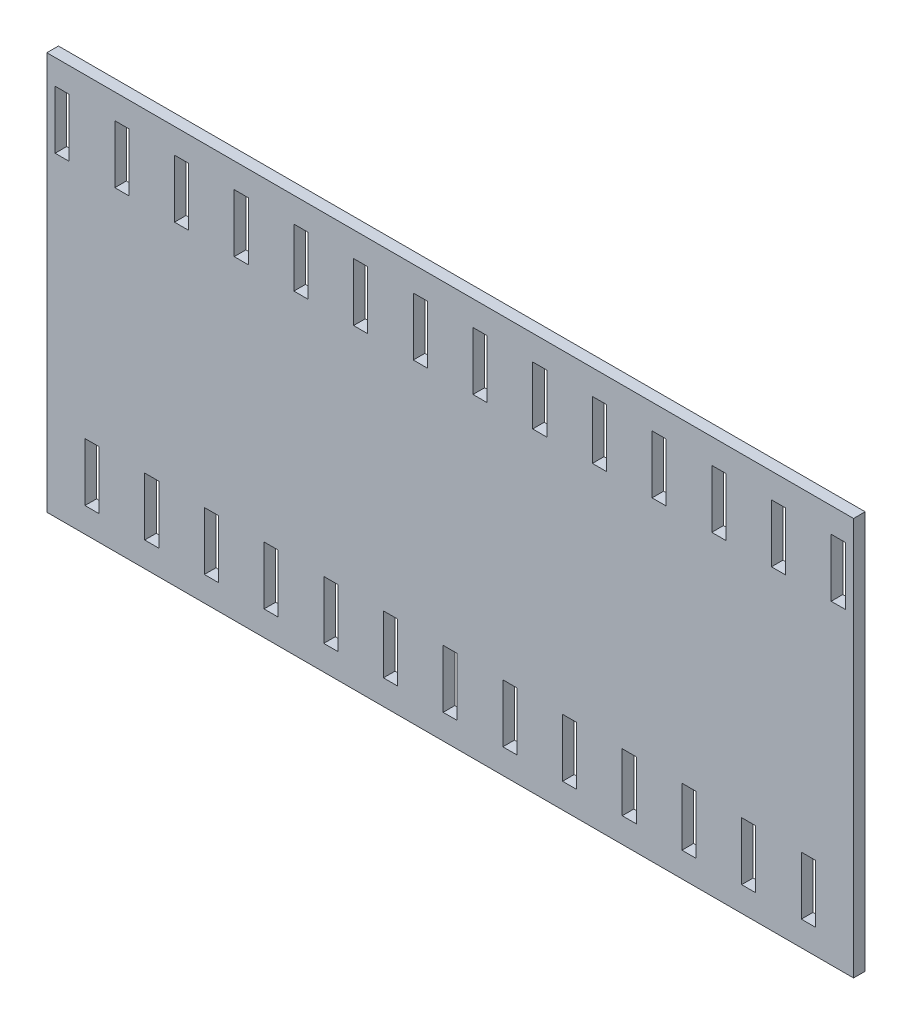
from build123d import *

# Parameters (mm, degrees)
ESQUISSE1_W             = 97.3
ESQUISSE1_H             = 48
BOSS_EXTRU_1_DEPTH      = 1.4
ESQUISSE2_W             = 1.7
ESQUISSE2_H             = 7
ENL_V_MAT_EXTRU_1_DEPTH = 2.4
ESQUISSE3_W             = 0.314102564
ESQUISSE3_H             = 3.5
ENL_V_MAT_EXTRU_2_DEPTH = 0.1


with BuildPart() as part:
    # Esquisse1 → Boss.-Extru.1 (new body)
    with BuildSketch(Plane.XY):
        Rectangle(ESQUISSE1_W, ESQUISSE1_H)
    extrude(amount=BOSS_EXTRU_1_DEPTH)

    # Esquisse2 → Enlèv. mat.-Extru.1 (cut, through all)
    with BuildSketch(Plane(origin=(0, 0, 0), x_dir=(-1, 0, 0), z_dir=(0, 0, -1))):
        with Locations((-46.8, 17.5)):
            Rectangle(ESQUISSE2_W, ESQUISSE2_H)
        with Locations((-39.6, 17.5)):
            Rectangle(ESQUISSE2_W, ESQUISSE2_H)
        with Locations((-32.4, 17.5)):
            Rectangle(ESQUISSE2_W, ESQUISSE2_H)
        with Locations((-25.2, 17.5)):
            Rectangle(ESQUISSE2_W, ESQUISSE2_H)
        with Locations((-18, 17.5)):
            Rectangle(ESQUISSE2_W, ESQUISSE2_H)
        with Locations((-10.8, 17.5)):
            Rectangle(ESQUISSE2_W, ESQUISSE2_H)
        with Locations((-3.6, 17.5)):
            Rectangle(ESQUISSE2_W, ESQUISSE2_H)
        with Locations((3.6, 17.5)):
            Rectangle(ESQUISSE2_W, ESQUISSE2_H)
        with Locations((10.8, 17.5)):
            Rectangle(ESQUISSE2_W, ESQUISSE2_H)
        with Locations((18, 17.5)):
            Rectangle(ESQUISSE2_W, ESQUISSE2_H)
        with Locations((25.2, 17.5)):
            Rectangle(ESQUISSE2_W, ESQUISSE2_H)
        with Locations((32.4, 17.5)):
            Rectangle(ESQUISSE2_W, ESQUISSE2_H)
        with Locations((39.6, 17.5)):
            Rectangle(ESQUISSE2_W, ESQUISSE2_H)
        with Locations((46.8, 17.5)):
            Rectangle(ESQUISSE2_W, ESQUISSE2_H)
        with Locations((-43.2, -17.5)):
            Rectangle(ESQUISSE2_W, ESQUISSE2_H)
        with Locations((-36, -17.5)):
            Rectangle(ESQUISSE2_W, ESQUISSE2_H)
        with Locations((-28.8, -17.5)):
            Rectangle(ESQUISSE2_W, ESQUISSE2_H)
        with Locations((-21.6, -17.5)):
            Rectangle(ESQUISSE2_W, ESQUISSE2_H)
        with Locations((-14.4, -17.5)):
            Rectangle(ESQUISSE2_W, ESQUISSE2_H)
        with Locations((-7.2, -17.5)):
            Rectangle(ESQUISSE2_W, ESQUISSE2_H)
        with Locations((0, -17.5)):
            Rectangle(ESQUISSE2_W, ESQUISSE2_H)
        with Locations((7.2, -17.5)):
            Rectangle(ESQUISSE2_W, ESQUISSE2_H)
        with Locations((14.4, -17.5)):
            Rectangle(ESQUISSE2_W, ESQUISSE2_H)
        with Locations((21.6, -17.5)):
            Rectangle(ESQUISSE2_W, ESQUISSE2_H)
        with Locations((28.8, -17.5)):
            Rectangle(ESQUISSE2_W, ESQUISSE2_H)
        with Locations((36, -17.5)):
            Rectangle(ESQUISSE2_W, ESQUISSE2_H)
        with Locations((43.2, -17.5)):
            Rectangle(ESQUISSE2_W, ESQUISSE2_H)
    extrude(amount=-ENL_V_MAT_EXTRU_1_DEPTH, mode=Mode.SUBTRACT)

    # Esquisse3 → Enlèv. mat.-Extru.2 (cut)
    with BuildSketch(Plane(origin=(0, 0, 0), x_dir=(-1, 0, 0), z_dir=(0, 0, -1))):
        Polygon((-10.734219848, 1.852513628), (-10.420117284, 1.852513628), (-10.420117284, 0.519681096), (-8.961082829, 1.852513628), (-8.513066002, 1.852513628), (-10.232917765, 0.282000808), (-8.378450618, -1.647486372), (-8.797020329, -1.647486372), (-10.420117284, 0.041516032), (-10.420117284, -1.647486372), (-10.734219848, -1.647486372), align=None)
        with BuildLine():
            Line((-7.862424977, 1.852513628), (-7.162004304, 1.852513628))
            add(Edge.make_bspline(
                [(-7.162004304, 1.852513628), (-7.115263175, 1.852358042), (-7.025515031, 1.8520593), (-6.89694176, 1.850393537), (-6.780114663, 1.845619181), (-6.675094824, 1.841510598), (-6.581884169, 1.834018656), (-6.500196878, 1.826858009), (-6.430409181, 1.817484348), (-6.388163329, 1.808778926), (-6.369035554, 1.804837346)],
                knots=[0, 0, 0, 0, 0.000140226, 0.00026925, 0.000385712, 0.000490995, 0.000584507, 0.000666202, 0.000736998, 0.000795574, 0.000795574, 0.000795574, 0.000795574], degree=3))
            add(Edge.make_bspline(
                [(-6.369035554, 1.804837346), (-6.343428929, 1.798510581), (-6.29276194, 1.785992017), (-6.219811874, 1.759532416), (-6.15029755, 1.728912792), (-6.084507726, 1.692949071), (-6.022771934, 1.651374292), (-5.964453624, 1.604906169), (-5.90928816, 1.553798963), (-5.85950653, 1.496764122), (-5.812567478, 1.436927612), (-5.772978852, 1.372223855), (-5.738852372, 1.304562328), (-5.711681855, 1.23325491), (-5.689803882, 1.158993138), (-5.674377642, 1.081104341), (-5.665126455, 0.999943366), (-5.664184599, 0.944585458), (-5.663707028, 0.916516032)],
                knots=[0, 0, 0, 0, 7.9081e-05, 0.000156475, 0.000232432, 0.000306798, 0.00038108, 0.000455429, 0.000530331, 0.000606314, 0.000682321, 0.000758201, 0.000833453, 0.000909362, 0.000986794, 0.001065445, 0.001147284, 0.001231465, 0.001231465, 0.001231465, 0.001231465], degree=3))
            add(Edge.make_bspline(
                [(-5.663707028, 0.916516032), (-5.665176026, 0.869880927), (-5.668042422, 0.778883759), (-5.694767525, 0.646822878), (-5.738544045, 0.523633563), (-5.798867334, 0.409470925), (-5.87568681, 0.30656028), (-5.968011601, 0.216169825), (-6.075893213, 0.140529912), (-6.176322528, 0.088077108), (-6.265036728, 0.054484199), (-6.338070041, 0.03084784), (-6.417737018, 0.012585875), (-6.503274353, -0.003774257), (-6.595038009, -0.016125951), (-6.692808048, -0.025172546), (-6.7966542, -0.030826595), (-6.867993269, -0.031668599), (-6.904692605, -0.032101757)],
                knots=[0, 0, 0, 0, 0.000139777, 0.000272741, 0.000402249, 0.000530843, 0.000658588, 0.000786009, 0.000916741, 0.001052522, 0.001124656, 0.001201155, 0.001282612, 0.001369656, 0.001462366, 0.001560247, 0.001664165, 0.001774261, 0.001774261, 0.001774261, 0.001774261], degree=3))
            Line((-6.904692605, -0.032101757), (-5.618835233, -1.647486372))
            Line((-5.618835233, -1.647486372), (-6.007256707, -1.647486372))
            Line((-6.007256707, -1.647486372), (-7.293114079, -0.032101757))
            Line((-7.293114079, -0.032101757), (-7.548322412, -0.032101757))
            Line((-7.548322412, -0.032101757), (-7.548322412, -1.647486372))
            Line((-7.548322412, -1.647486372), (-7.862424977, -1.647486372))
            Line((-7.862424977, -1.647486372), (-7.862424977, 1.852513628))
        make_face()
        with BuildLine():
            Line((-7.548322412, 1.493539269), (-7.548322412, 0.326872602))
            Line((-7.548322412, 0.326872602), (-6.907497092, 0.32196475))
            add(Edge.make_bspline(
                [(-6.907497092, 0.32196475), (-6.877577053, 0.321951513), (-6.819583496, 0.321925857), (-6.735682831, 0.325919633), (-6.657562719, 0.330462951), (-6.585521967, 0.337412297), (-6.519528392, 0.346368369), (-6.459614979, 0.357571353), (-6.405683927, 0.370623415), (-6.342785388, 0.390825041), (-6.272548857, 0.42283106), (-6.196217397, 0.469396558), (-6.131215059, 0.527965677), (-6.076297197, 0.594939133), (-6.032167766, 0.668575382), (-6.001055711, 0.747991751), (-5.981313269, 0.83118335), (-5.978984724, 0.888361457), (-5.977809592, 0.917217154)],
                knots=[0, 0, 0, 0, 8.9746e-05, 0.000173954, 0.000251933, 0.000324488, 0.000391021, 0.000451663, 0.000507268, 0.000557378, 0.000649639, 0.000738152, 0.000824558, 0.000910739, 0.000997194, 0.001080909, 0.00116578, 0.001252248, 0.001252248, 0.001252248, 0.001252248], degree=3))
            add(Edge.make_bspline(
                [(-5.977809592, 0.917217154), (-5.979011713, 0.945363727), (-5.981393878, 1.001139966), (-6.000842647, 1.082795876), (-6.033732028, 1.159862827), (-6.078054266, 1.232027312), (-6.132053421, 1.297533047), (-6.195371234, 1.3535802), (-6.266276429, 1.399829665), (-6.332547627, 1.429384046), (-6.39178184, 1.447503899), (-6.4432115, 1.460255063), (-6.501322978, 1.470499532), (-6.566398436, 1.478707593), (-6.638160067, 1.485762537), (-6.716970718, 1.490514315), (-6.802307498, 1.49332818), (-6.86145443, 1.493467268), (-6.892072412, 1.493539269)],
                knots=[0, 0, 0, 0, 8.4371e-05, 0.000167192, 0.000250141, 0.000334794, 0.000420435, 0.000503871, 0.000587493, 0.000673488, 0.0007205, 0.000773215, 0.000832351, 0.0008974, 0.000969955, 0.001048634, 0.001134217, 0.001226067, 0.001226067, 0.001226067, 0.001226067], degree=3))
            Line((-6.892072412, 1.493539269), (-7.548322412, 1.493539269))
        make_face(mode=Mode.SUBTRACT)
        with BuildLine():
            Line((-0.862424977, -1.647486372), (-0.862424977, 1.852513628))
            Line((-0.862424977, 1.852513628), (-0.155694207, 1.852513628))
            add(Edge.make_bspline(
                [(-0.155694207, 1.852513628), (-0.094225219, 1.852071058), (0.024532546, 1.851216015), (0.196144994, 1.845794624), (0.354928756, 1.836204158), (0.500361615, 1.822234632), (0.632842827, 1.805081598), (0.752001435, 1.783581194), (0.858453578, 1.758193024), (0.923923019, 1.736547573), (0.954882716, 1.726311705)],
                knots=[0, 0, 0, 0, 0.000184407, 0.000356273, 0.000515031, 0.000661537, 0.000794508, 0.000915664, 0.001024665, 0.001122454, 0.001122454, 0.001122454, 0.001122454], degree=3))
            add(Edge.make_bspline(
                [(0.954882716, 1.726311705), (0.995377455, 1.710880999), (1.075448647, 1.680369505), (1.18945577, 1.622813204), (1.296781133, 1.557600102), (1.398000278, 1.48464424), (1.490801104, 1.401879891), (1.578809001, 1.312822805), (1.658423725, 1.214234465), (1.731332021, 1.108159477), (1.79706768, 0.995847425), (1.854206838, 0.877512316), (1.901660831, 0.753755108), (1.941054058, 0.62491996), (1.972100515, 0.490723582), (1.993282447, 0.351009716), (2.007253437, 0.206330527), (2.008657488, 0.108156063), (2.009369895, 0.058342955)],
                knots=[0, 0, 0, 0, 0.000129935, 0.000256923, 0.000382457, 0.000506429, 0.000630624, 0.000755071, 0.000881654, 0.001010204, 0.001140916, 0.00127168, 0.001403968, 0.001538146, 0.001675568, 0.001816774, 0.001961818, 0.002111216, 0.002111216, 0.002111216, 0.002111216], degree=3))
            add(Edge.make_bspline(
                [(2.009369895, 0.058342955), (2.008740928, 0.015081717), (2.007501482, -0.070169072), (1.996372166, -0.195809968), (1.980195846, -0.317723539), (1.955151648, -0.435329239), (1.924749134, -0.549657457), (1.885784983, -0.659489702), (1.841149487, -0.765833511), (1.789099608, -0.867250987), (1.731958223, -0.963334359), (1.67063648, -1.053909887), (1.605199785, -1.137685109), (1.535024152, -1.214913721), (1.461016435, -1.2854793), (1.382692105, -1.349971315), (1.299849054, -1.40712787), (1.212858331, -1.459194978), (1.119182202, -1.504615334), (1.017046336, -1.543045343), (0.906015158, -1.574891959), (0.786361201, -1.601462854), (0.657877723, -1.622540157), (0.520438757, -1.63666655), (0.374255468, -1.646219482), (0.273876203, -1.647055876), (0.22221044, -1.647486372)],
                knots=[0, 0, 0, 0, 0.000129755, 0.000255696, 0.000378151, 0.000498469, 0.000616165, 0.000732801, 0.000847787, 0.000961923, 0.00107447, 0.001182981, 0.001289856, 0.001393094, 0.001495748, 0.001596383, 0.00169713, 0.001797413, 0.001900265, 0.002008995, 0.002124372, 0.002246504, 0.002376522, 0.002514729, 0.002660846, 0.00281582, 0.00281582, 0.00281582, 0.00281582], degree=3))
            Line((0.22221044, -1.647486372), (-0.862424977, -1.647486372))
        make_face()
        with BuildLine():
            Line((-0.548322412, -1.288512013), (-0.146579624, -1.288512013))
            add(Edge.make_bspline(
                [(-0.146579624, -1.288512013), (-0.088851253, -1.288263917), (0.022181545, -1.287786736), (0.181839542, -1.283599533), (0.327718939, -1.276757596), (0.459840448, -1.267182518), (0.578129473, -1.254513903), (0.682833222, -1.240389), (0.773608481, -1.222791549), (0.828537918, -1.20684059), (0.853921177, -1.199469545)],
                knots=[0, 0, 0, 0, 0.000173183, 0.000333094, 0.000479096, 0.000611272, 0.000730431, 0.000835931, 0.000928194, 0.001007458, 0.001007458, 0.001007458, 0.001007458], degree=3))
            add(Edge.make_bspline(
                [(0.853921177, -1.199469545), (0.885869539, -1.188217987), (0.949003178, -1.165983613), (1.039884263, -1.125425952), (1.124641267, -1.077383883), (1.204751293, -1.023981609), (1.279077948, -0.963335607), (1.348502064, -0.896764618), (1.412883866, -0.823929843), (1.471558174, -0.744921681), (1.524066478, -0.660231885), (1.569537707, -0.570693052), (1.609389239, -0.477286242), (1.640667831, -0.378577083), (1.665183416, -0.275448025), (1.682548104, -0.167891811), (1.693362828, -0.055928529), (1.694624276, 0.020223595), (1.695267331, 0.059044077)],
                knots=[0, 0, 0, 0, 0.000101593, 0.000200759, 0.000298073, 0.000393552, 0.000489254, 0.000585454, 0.000681817, 0.000780535, 0.000880346, 0.000980374, 0.001081551, 0.001184655, 0.001290601, 0.001399295, 0.001511268, 0.001627707, 0.001627707, 0.001627707, 0.001627707], degree=3))
            add(Edge.make_bspline(
                [(1.695267331, 0.059044077), (1.694754044, 0.099977557), (1.693745686, 0.180391741), (1.681071376, 0.298382437), (1.66254982, 0.411863087), (1.635766134, 0.520841283), (1.601635255, 0.625529635), (1.559040614, 0.725349145), (1.510373994, 0.821354014), (1.452470657, 0.91132838), (1.389055064, 0.996421489), (1.318677185, 1.074376404), (1.242455146, 1.145370705), (1.161220297, 1.210510017), (1.072683198, 1.267173693), (0.978929507, 1.317860374), (0.878583836, 1.360876266), (0.80877114, 1.383755128), (0.773292171, 1.395382218)],
                knots=[0, 0, 0, 0, 0.000122746, 0.000241136, 0.000355593, 0.000467485, 0.000577457, 0.000685538, 0.00079278, 0.000899951, 0.001006101, 0.00111085, 0.001214524, 0.001318328, 0.001422759, 0.001529413, 0.00163777, 0.001749741, 0.001749741, 0.001749741, 0.001749741], degree=3))
            add(Edge.make_bspline(
                [(0.773292171, 1.395382218), (0.743941024, 1.403498646), (0.681532434, 1.420756398), (0.57969297, 1.439581771), (0.465077821, 1.45618627), (0.33717812, 1.470244309), (0.196139661, 1.480331631), (0.041853973, 1.487902945), (-0.125745632, 1.493009578), (-0.241928166, 1.493358285), (-0.302228662, 1.493539269)],
                knots=[0, 0, 0, 0, 9.1321e-05, 0.000194173, 0.000310382, 0.000438754, 0.000580072, 0.000734511, 0.000902151, 0.001083046, 0.001083046, 0.001083046, 0.001083046], degree=3))
            Line((-0.302228662, 1.493539269), (-0.548322412, 1.493539269))
            Line((-0.548322412, 1.493539269), (-0.548322412, -1.288512013))
        make_face(mode=Mode.SUBTRACT)
        with BuildLine():
            Line((2.727318613, 1.852513628), (3.427739286, 1.852513628))
            add(Edge.make_bspline(
                [(3.427739286, 1.852513628), (3.474480415, 1.852358042), (3.564228559, 1.8520593), (3.69280183, 1.850393537), (3.809628927, 1.845619181), (3.914648766, 1.841510598), (4.007859421, 1.834018656), (4.089546712, 1.826858009), (4.159334409, 1.817484348), (4.20158026, 1.808778926), (4.220708036, 1.804837346)],
                knots=[0, 0, 0, 0, 0.000140226, 0.00026925, 0.000385712, 0.000490995, 0.000584507, 0.000666202, 0.000736998, 0.000795574, 0.000795574, 0.000795574, 0.000795574], degree=3))
            add(Edge.make_bspline(
                [(4.220708036, 1.804837346), (4.24631466, 1.798510581), (4.29698165, 1.785992017), (4.369931716, 1.759532416), (4.43944604, 1.728912792), (4.505235864, 1.692949071), (4.566971655, 1.651374292), (4.625289966, 1.604906169), (4.68045543, 1.553798963), (4.73023706, 1.496764122), (4.777176111, 1.436927612), (4.816764738, 1.372223855), (4.850891218, 1.304562328), (4.878061735, 1.23325491), (4.899939708, 1.158993138), (4.915365947, 1.081104341), (4.924617135, 0.999943366), (4.925558991, 0.944585458), (4.926036562, 0.916516032)],
                knots=[0, 0, 0, 0, 7.9081e-05, 0.000156475, 0.000232432, 0.000306798, 0.00038108, 0.000455429, 0.000530331, 0.000606314, 0.000682321, 0.000758201, 0.000833453, 0.000909362, 0.000986794, 0.001065445, 0.001147284, 0.001231465, 0.001231465, 0.001231465, 0.001231465], degree=3))
            add(Edge.make_bspline(
                [(4.926036562, 0.916516032), (4.924567564, 0.869880927), (4.921701168, 0.778883759), (4.894976064, 0.646822878), (4.851199545, 0.523633563), (4.790876256, 0.409470925), (4.71405678, 0.30656028), (4.621731989, 0.216169825), (4.513850377, 0.140529912), (4.413421061, 0.088077108), (4.324706862, 0.054484199), (4.251673549, 0.03084784), (4.172006571, 0.012585875), (4.086469237, -0.003774257), (3.994705581, -0.016125951), (3.896935542, -0.025172546), (3.79308939, -0.030826595), (3.721750321, -0.031668599), (3.685050985, -0.032101757)],
                knots=[0, 0, 0, 0, 0.000139777, 0.000272741, 0.000402249, 0.000530843, 0.000658588, 0.000786009, 0.000916741, 0.001052522, 0.001124656, 0.001201155, 0.001282612, 0.001369656, 0.001462366, 0.001560247, 0.001664165, 0.001774261, 0.001774261, 0.001774261, 0.001774261], degree=3))
            Line((3.685050985, -0.032101757), (4.970908357, -1.647486372))
            Line((4.970908357, -1.647486372), (4.582486882, -1.647486372))
            Line((4.582486882, -1.647486372), (3.296629511, -0.032101757))
            Line((3.296629511, -0.032101757), (3.041421177, -0.032101757))
            Line((3.041421177, -0.032101757), (3.041421177, -1.647486372))
            Line((3.041421177, -1.647486372), (2.727318613, -1.647486372))
            Line((2.727318613, -1.647486372), (2.727318613, 1.852513628))
        make_face()
        with BuildLine():
            Line((3.041421177, 1.493539269), (3.041421177, 0.326872602))
            Line((3.041421177, 0.326872602), (3.682246498, 0.32196475))
            add(Edge.make_bspline(
                [(3.682246498, 0.32196475), (3.712166537, 0.321951513), (3.770160094, 0.321925857), (3.854060759, 0.325919633), (3.93218087, 0.330462951), (4.004221622, 0.337412297), (4.070215198, 0.346368369), (4.130128611, 0.357571353), (4.184059663, 0.370623415), (4.246958201, 0.390825041), (4.317194733, 0.42283106), (4.393526193, 0.469396558), (4.45852853, 0.527965677), (4.513446393, 0.594939133), (4.557575824, 0.668575382), (4.588687878, 0.747991751), (4.608430321, 0.83118335), (4.610758866, 0.888361457), (4.611933998, 0.917217154)],
                knots=[0, 0, 0, 0, 8.9746e-05, 0.000173954, 0.000251933, 0.000324488, 0.000391021, 0.000451663, 0.000507268, 0.000557378, 0.000649639, 0.000738152, 0.000824558, 0.000910739, 0.000997194, 0.001080909, 0.00116578, 0.001252248, 0.001252248, 0.001252248, 0.001252248], degree=3))
            add(Edge.make_bspline(
                [(4.611933998, 0.917217154), (4.610731877, 0.945363727), (4.608349711, 1.001139966), (4.588900943, 1.082795876), (4.556011561, 1.159862827), (4.511689324, 1.232027312), (4.457690169, 1.297533047), (4.394372356, 1.3535802), (4.323467161, 1.399829665), (4.257195962, 1.429384046), (4.19796175, 1.447503899), (4.14653209, 1.460255063), (4.088420612, 1.470499532), (4.023345153, 1.478707593), (3.951583523, 1.485762537), (3.872772872, 1.490514315), (3.787436091, 1.49332818), (3.72828916, 1.493467268), (3.697671177, 1.493539269)],
                knots=[0, 0, 0, 0, 8.4371e-05, 0.000167192, 0.000250141, 0.000334794, 0.000420435, 0.000503871, 0.000587493, 0.000673488, 0.0007205, 0.000773215, 0.000832351, 0.0008974, 0.000969955, 0.001048634, 0.001134217, 0.001226067, 0.001226067, 0.001226067, 0.001226067], degree=3))
            Line((3.697671177, 1.493539269), (3.041421177, 1.493539269))
        make_face(mode=Mode.SUBTRACT)
        with Locations((5.845908357, 0.102513628)):
            Rectangle(ESQUISSE3_W, ESQUISSE3_H)
        Polygon((6.900395536, 1.852513628), (8.605523741, 1.852513628), (8.605523741, 1.493539269), (7.2144981, 1.493539269), (7.2144981, 0.416616192), (8.605523741, 0.416616192), (8.605523741, 0.057641833), (7.2144981, 0.057641833), (7.2144981, -1.647486372), (6.900395536, -1.647486372), align=None)
        Polygon((8.829882716, 1.493539269), (8.829882716, 1.852513628), (10.669626305, 1.852513628), (10.669626305, 1.493539269), (9.906805793, 1.493539269), (9.906805793, -1.647486372), (9.592703229, -1.647486372), (9.592703229, 1.493539269), align=None)
    extrude(amount=-ENL_V_MAT_EXTRU_2_DEPTH, mode=Mode.SUBTRACT)


solid = part.part
